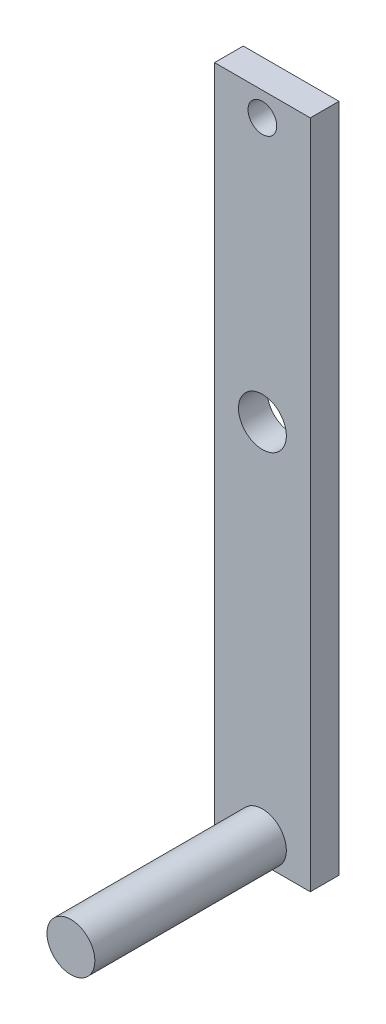
from build123d import *

# Parameters (mm, degrees)
SKETCH1_W           = 10
SKETCH1_H           = 70
BOSS_EXTRUDE1_DEPTH = 3
SKETCH2_R           = 2.5
BOSS_EXTRUDE2_DEPTH = 20
SKETCH4_R           = 1.5
CUT_EXTRUDE1_DEPTH  = 20
SKETCH3_R           = 2.5
CUT_EXTRUDE3_DEPTH  = 20


with BuildPart() as part:
    # Sketch1 → Boss-Extrude1 (new body)
    with BuildSketch(Plane.XY):
        with Locations((5, 35)):
            Rectangle(SKETCH1_W, SKETCH1_H)
    extrude(amount=BOSS_EXTRUDE1_DEPTH)

    # Sketch2 → Boss-Extrude2 (add)
    with BuildSketch(Plane.XY.offset(3)):
        with Locations((5, 2.5)):
            Circle(SKETCH2_R)
    extrude(amount=BOSS_EXTRUDE2_DEPTH)

    # Sketch4 → Cut-Extrude1 (cut)
    with BuildSketch(Plane(origin=(0, 0, 0), x_dir=(-1, 0, 0), z_dir=(0, 0, -1))):
        with Locations((-5, 67.5)):
            Circle(SKETCH4_R)
    extrude(amount=-CUT_EXTRUDE1_DEPTH, mode=Mode.SUBTRACT)

    # Sketch3 → Cut-Extrude3 (cut)
    with BuildSketch(Plane(origin=(0, 0, 0), x_dir=(-1, 0, 0), z_dir=(0, 0, -1))):
        with Locations((-5, 40)):
            Circle(SKETCH3_R)
    extrude(amount=-CUT_EXTRUDE3_DEPTH, mode=Mode.SUBTRACT)


solid = part.part
